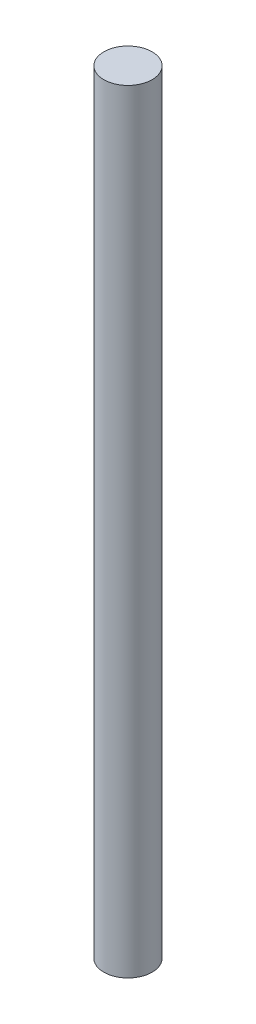
from build123d import *

# Parameters (mm, degrees)
SKETCH1_R           = 3.175
BOSS_EXTRUDE1_DEPTH = 101.6


with BuildPart() as part:
    # Sketch1 → Boss-Extrude1 (new body)
    with BuildSketch(Plane(origin=(0, 0, 0), x_dir=(1, 0, 0), z_dir=(0, 1, 0))):
        with Locations(Location((0, 0, 0), (0, 0, 270))):  # turned: the seam where the file's is
            Circle(SKETCH1_R)
    extrude(amount=BOSS_EXTRUDE1_DEPTH)


solid = part.part
